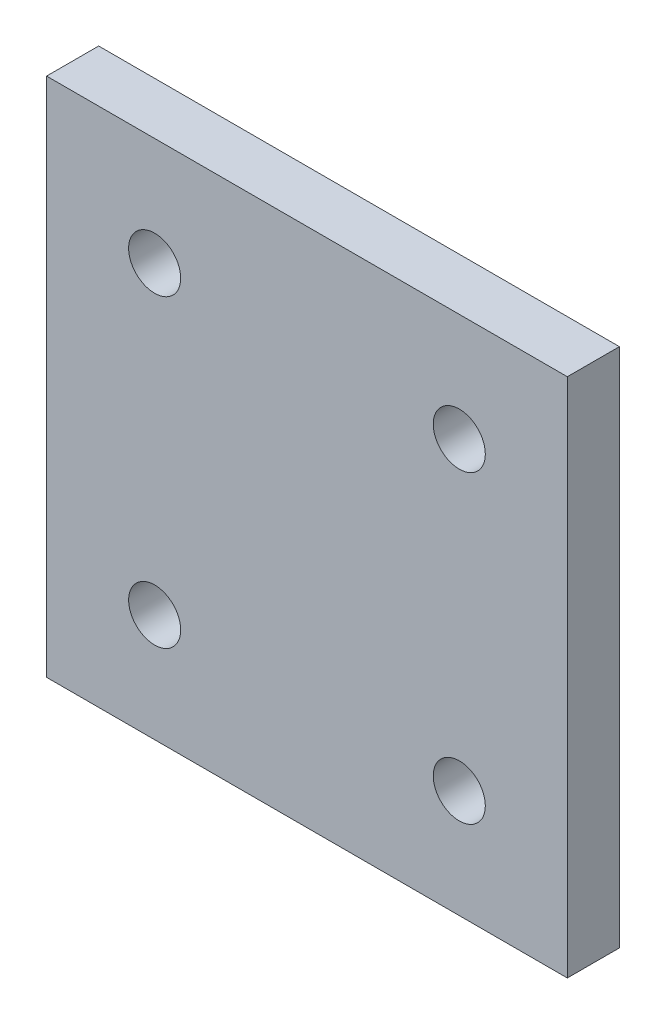
from build123d import *

# Parameters (mm, degrees)
SZKIC1_W                    = 90
SZKIC1_H                    = 90
SZKIC1_R                    = 6
DODANIE_WYCI_GNI_CIE1_DEPTH = 12
SZKIC2_W                    = 120
SZKIC2_H                    = 120
SZKIC2_W_2                  = 90
SZKIC2_H_2                  = 90
DODANIE_WYCI_GNI_CIE3_DEPTH = 12


with BuildPart() as part:
    # Szkic1 → Dodanie-wyciągnięcie1 (new body)
    with BuildSketch(Plane.XY):
        with Locations((10.517420564, -9.685096154)):
            Rectangle(SZKIC1_W, SZKIC1_H)
        with Locations((-24.583084499, 25.41540891)):
            Circle(SZKIC1_R, mode=Mode.SUBTRACT)
        with Locations((-24.583084499, -44.785601217)):
            Circle(SZKIC1_R, mode=Mode.SUBTRACT)
        with Locations((45.617925627, -44.785601217)):
            Circle(SZKIC1_R, mode=Mode.SUBTRACT)
        with Locations((45.617925627, 25.41540891)):
            Circle(SZKIC1_R, mode=Mode.SUBTRACT)
    extrude(amount=DODANIE_WYCI_GNI_CIE1_DEPTH)

    # Szkic2 → Dodanie-wyciągnięcie3 (add)
    with BuildSketch(Plane.XY.offset(12)):
        with Locations((10.517420564, -9.685096154)):
            Rectangle(SZKIC2_W, SZKIC2_H)
        with Locations((10.517420564, -9.685096154)):
            Rectangle(SZKIC2_W_2, SZKIC2_H_2, mode=Mode.SUBTRACT)
    extrude(amount=-DODANIE_WYCI_GNI_CIE3_DEPTH)


solid = part.part
